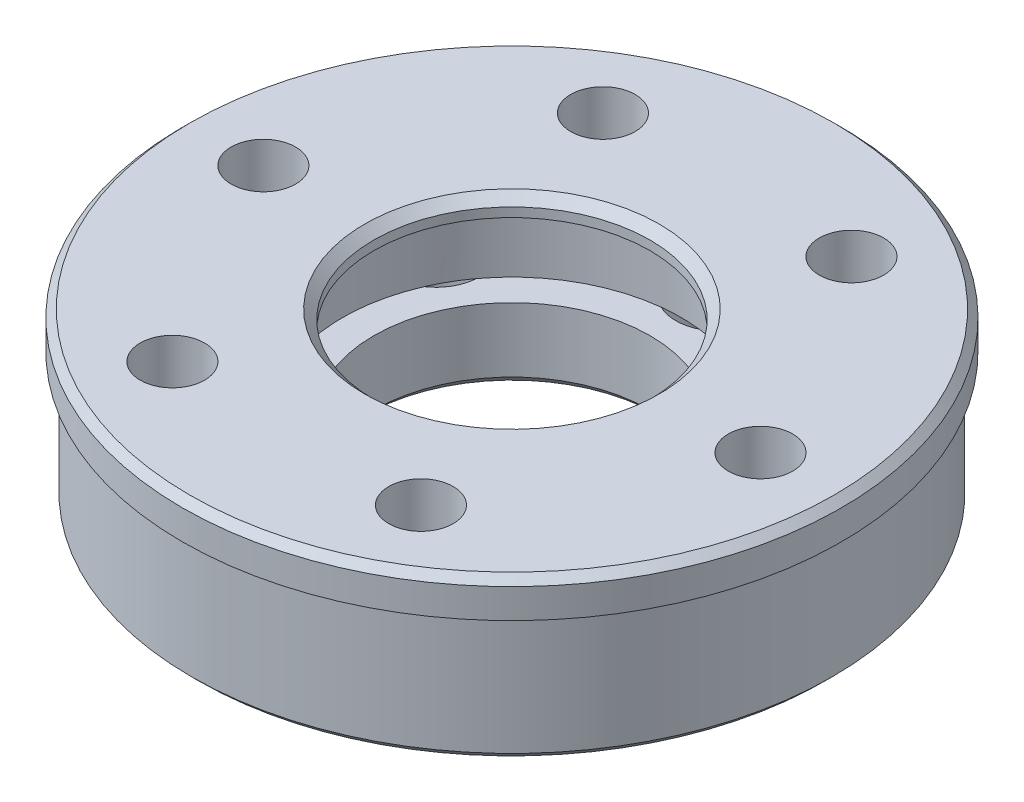
from build123d import *

# Parameters (mm, degrees)
SKETCH1_R           = 17.4
SKETCH1_R_2         = 1.75
SKETCH1_R_3         = 7.5
BOSS_EXTRUDE1_DEPTH = 4.5
CUT_EXTRUDE1_START  = -0.5
SKETCH2_R           = 9.2
CUT_EXTRUDE1_DEPTH  = 4
SKETCH3_R           = 15.25
SKETCH3_R_2         = 11.75
BOSS_EXTRUDE2_DEPTH = 1.5
CHAMFER1_SIZE       = 0.5
SKETCH4_R           = 17.9
SKETCH4_R_2         = 17.4
BOSS_EXTRUDE3_DEPTH = 2
SKETCH5_R           = 2.35
CUT_EXTRUDE2_DEPTH  = 4
CHAMFER3_SIZE       = 0.4


with BuildPart() as part:
    # Sketch1 → Boss-Extrude1 (new body, symmetric)
    with BuildSketch(Plane(origin=(0, 0, 0), x_dir=(1, 0, 0), z_dir=(0, 1, 0))):
        Circle(SKETCH1_R)
        with Locations((13.5, 0)):
            Circle(SKETCH1_R_2, mode=Mode.SUBTRACT)
        with Locations((6.75, -11.691342951)):
            Circle(SKETCH1_R_2, mode=Mode.SUBTRACT)
        with Locations((-6.75, -11.691342951)):
            Circle(SKETCH1_R_2, mode=Mode.SUBTRACT)
        with Locations((-13.5, 0)):
            Circle(SKETCH1_R_2, mode=Mode.SUBTRACT)
        with Locations((-6.75, 11.691342951)):
            Circle(SKETCH1_R_2, mode=Mode.SUBTRACT)
        with Locations((6.75, 11.691342951)):
            Circle(SKETCH1_R_2, mode=Mode.SUBTRACT)
        Circle(SKETCH1_R_3, mode=Mode.SUBTRACT)
    extrude(amount=BOSS_EXTRUDE1_DEPTH, both=True)

    # Sketch2 → Cut-Extrude1 (cut)
    with BuildSketch(Plane(origin=(0, 0, 0), x_dir=(1, 0, 0), z_dir=(0, 1, 0)).offset(CUT_EXTRUDE1_START)):
        Circle(SKETCH2_R)
    extrude(amount=CUT_EXTRUDE1_DEPTH, mode=Mode.SUBTRACT)

    # Sketch3 → Boss-Extrude2 (add)
    with BuildSketch(Plane.XZ.offset(4.5)):
        Circle(SKETCH3_R)
        Circle(SKETCH3_R_2, mode=Mode.SUBTRACT)
    extrude(amount=-BOSS_EXTRUDE2_DEPTH)

    # Chamfer1
    chamfer1_edges = [part.edges().sort_by_distance(p)[0] for p in [
        (-7.5, -4.5, 0),
        (-7.5, 4.5, 0),
    ]]
    chamfer(chamfer1_edges, length=CHAMFER1_SIZE)

    # Sketch4 → Boss-Extrude3 (add)
    with BuildSketch(Plane(origin=(0, 4.5, 0), x_dir=(1, 0, 0), z_dir=(0, 1, 0))):
        Circle(SKETCH4_R)
        Circle(SKETCH4_R_2, mode=Mode.SUBTRACT)
    extrude(amount=-BOSS_EXTRUDE3_DEPTH)

    # Sketch5 → Cut-Extrude2 (cut)
    with BuildSketch(Plane(origin=(0, -4.5, 0), x_dir=(-1, 0, 0), z_dir=(0, -1, 0))):
        with Locations((-9.742785793, -5.625)):
            Circle(SKETCH5_R)
        with Locations((-9.742785793, 5.625)):
            Circle(SKETCH5_R)
        with Locations((0, 11.25)):
            Circle(SKETCH5_R)
        with Locations((9.742785793, 5.625)):
            Circle(SKETCH5_R)
        with Locations((9.742785793, -5.625)):
            Circle(SKETCH5_R)
        with Locations((0, -11.25)):
            Circle(SKETCH5_R)
    extrude(amount=-CUT_EXTRUDE2_DEPTH, mode=Mode.SUBTRACT)

    # Chamfer3
    chamfer3_edges = [part.edges().sort_by_distance(p)[0] for p in [
        (-17.9, 4.5, 0),
        (-17.4, -4.5, 0),
    ]]
    chamfer(chamfer3_edges, length=CHAMFER3_SIZE)


solid = part.part
